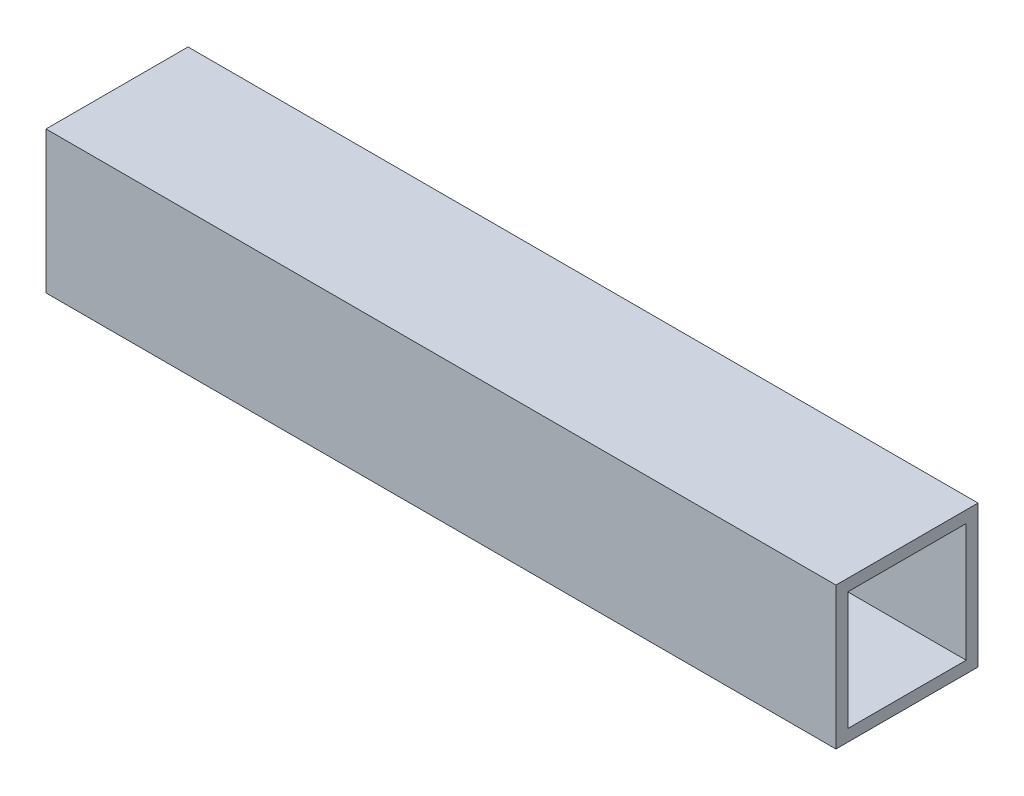
from build123d import *

# Parameters (mm, degrees)
SKETCH1_W               = 211.9
SKETCH1_H               = 38.1
BOSS_EXTRUDE1_DEPTH     = 38.1
SKETCH2_W               = 31.75
SKETCH2_H               = 31.75
CUT_EXTRUDE1_DEPTH      = 1
CUT_EXTRUDE1_DEPTH_BACK = 212.9


with BuildPart() as part:
    # Sketch1 → Boss-Extrude1 (new body)
    with BuildSketch(Plane.XY):
        with Locations((105.95, 19.05)):
            Rectangle(SKETCH1_W, SKETCH1_H)
    extrude(amount=-BOSS_EXTRUDE1_DEPTH)

    # Sketch2 → Cut-Extrude1 (cut, two sides)
    with BuildSketch(Plane(origin=(211.9, 0, 0), x_dir=(0, 0, -1), z_dir=(1, 0, 0))) as cut_extrude1_sk:
        with Locations((19.05, 19.05)):
            Rectangle(SKETCH2_W, SKETCH2_H)
    extrude(amount=CUT_EXTRUDE1_DEPTH, mode=Mode.SUBTRACT)
    extrude(cut_extrude1_sk.sketch, amount=-CUT_EXTRUDE1_DEPTH_BACK, mode=Mode.SUBTRACT)


solid = part.part
